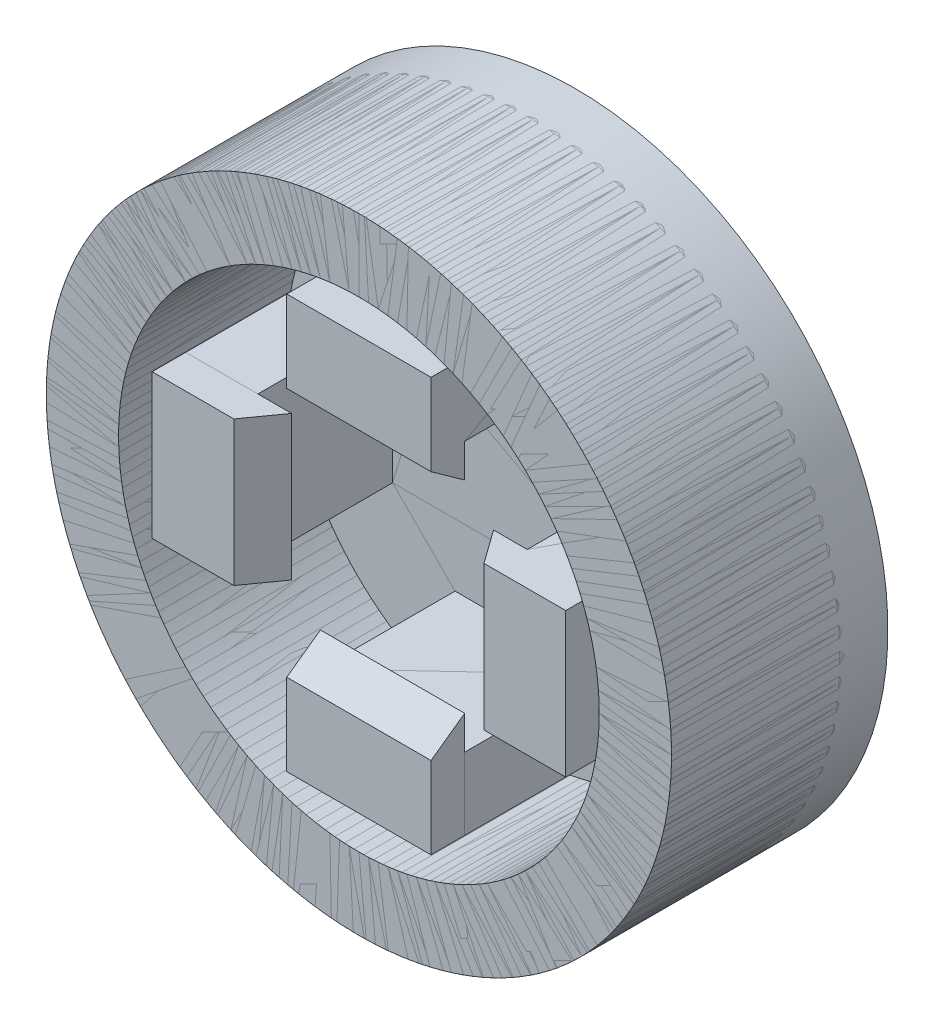
from build123d import *

# Parameters (mm, degrees)
ESQUISSE1_R                   = 6.5
BOSS_EXTRU_1_DEPTH            = 1
ESQUISSE2_R                   = 6.5
ESQUISSE2_R_2                 = 5
BOSS_EXTRU_2_DEPTH            = 3.5
ESQUISSE3_W                   = 1.5
ESQUISSE3_H                   = 3
ESQUISSE3_W_2                 = 3
ESQUISSE3_H_2                 = 1.5
BOSS_EXTRU_3_DEPTH            = 2.8
BOSS_EXTRU_4_DEPTH            = 3
R_P_TITION_CIRCULAIRE10_COUNT = 4


with BuildPart() as part:
    # Esquisse1 → Boss.-Extru.1 (new body)
    with BuildSketch(Plane.XY):
        Circle(ESQUISSE1_R)
    extrude(amount=BOSS_EXTRU_1_DEPTH)

    # Esquisse2 → Boss.-Extru.2 (add)
    with BuildSketch(Plane.XY.offset(1)):
        Circle(ESQUISSE2_R)
        Circle(ESQUISSE2_R_2, mode=Mode.SUBTRACT)
    extrude(amount=BOSS_EXTRU_2_DEPTH)

    # Esquisse3 → Boss.-Extru.3 (add)
    with BuildSketch(Plane.XY.offset(1)):
        with Locations((3.55, 0)):
            Rectangle(ESQUISSE3_W, ESQUISSE3_H)
        with Locations((0, 3.55)):
            Rectangle(ESQUISSE3_W_2, ESQUISSE3_H_2)
        with Locations((0, -3.55)):
            Rectangle(ESQUISSE3_W_2, ESQUISSE3_H_2)
        with Locations((-3.55, 0)):
            Rectangle(ESQUISSE3_W, ESQUISSE3_H)
    extrude(amount=BOSS_EXTRU_3_DEPTH)

    # Esquisse4 → Boss.-Extru.4 (add)
    with BuildSketch(Plane.ZY.offset(1.5)):
        Polygon((3.8, 4.3), (3.8, 2.1), (4.5, 2.6), (4.5, 4.3), align=None)
    extrude(amount=-BOSS_EXTRU_4_DEPTH)


with BuildPart() as r_p_tition_circulaire10_1:
    # Répétition circulaire10: pattern copy
    add(part.part.rotate(Axis((0, 0, 0), (0, 0, 1)), 1 * 360 / R_P_TITION_CIRCULAIRE10_COUNT))


with BuildPart() as r_p_tition_circulaire10_2:
    # Répétition circulaire10: pattern copy
    add(part.part.rotate(Axis((0, 0, 0), (0, 0, 1)), 2 * 360 / R_P_TITION_CIRCULAIRE10_COUNT))


with BuildPart() as r_p_tition_circulaire10_3:
    # Répétition circulaire10: pattern copy
    add(part.part.rotate(Axis((0, 0, 0), (0, 0, 1)), 3 * 360 / R_P_TITION_CIRCULAIRE10_COUNT))


with BuildPart() as enl_vement_de_mati_re_r_volution1_tool:
    # Esquisse5 → Enlèvement de matière-Révolution1 (revolve)
    with BuildSketch(Plane(origin=(0, 0, 0), x_dir=(0, 0, -1), z_dir=(1, 0, 0))):
        with BuildLine():
            Line((0, -6.5), (-1, -6.5))
            ThreePointArc((-1, -6.5), (-0.292893219, -6.207106781), (0, -5.5))
            Line((0, -5.5), (0, -6.5))
        make_face()
    revolve(axis=Axis((0, 0, 1), (0, 0, -1)))


with BuildPart() as part_1:
    add(part.part)

    # Enlèvement de matière-Révolution1: cut by enl_vement_de_mati_re_r_volution1_tool
    add(enl_vement_de_mati_re_r_volution1_tool.part, mode=Mode.SUBTRACT)


with BuildPart() as r_p_tition_circulaire10_1_1:
    add(r_p_tition_circulaire10_1.part)

    # Enlèvement de matière-Révolution1: cut by enl_vement_de_mati_re_r_volution1_tool
    add(enl_vement_de_mati_re_r_volution1_tool.part, mode=Mode.SUBTRACT)


with BuildPart() as r_p_tition_circulaire10_3_1:
    add(r_p_tition_circulaire10_3.part)

    # Enlèvement de matière-Révolution1: cut by enl_vement_de_mati_re_r_volution1_tool
    add(enl_vement_de_mati_re_r_volution1_tool.part, mode=Mode.SUBTRACT)


solid = Compound([r_p_tition_circulaire10_2.part, part_1.part, r_p_tition_circulaire10_1_1.part, r_p_tition_circulaire10_3_1.part])
